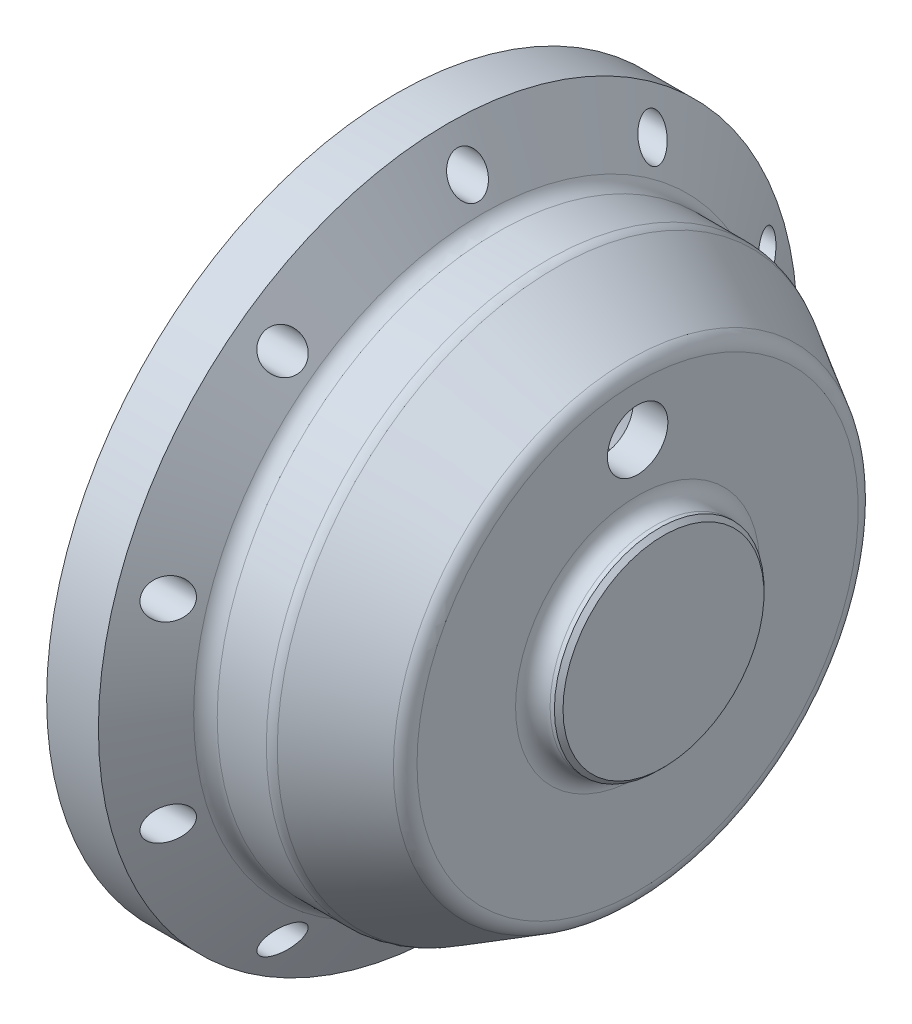
from build123d import *

# Parameters (mm, degrees)
CIRPATTERN1_COUNT        = 10
F_7_0_7_DIAMETER_HOLE1_D = 7


with BuildPart() as part:
    # Sketch1 → Revolve1 (revolve)
    with BuildSketch(Plane.XY):
        with BuildLine():
            Line((0, 40.5), (0, 30.475))
            Line((0, 30.475), (-1, 30.475))
            Line((-1, 30.475), (-1, 25.475))
            Line((-1, 25.475), (22, 25.475))
            ThreePointArc((22, 25.475), (23.414213562, 24.889213562), (24, 23.475))
            Line((24, 23.475), (24, 12.65))
            ThreePointArc((24, 12.65), (23.853553391, 12.296446609), (23.5, 12.15))
            Line((23.5, 12.15), (7.5, 12.15))
            Line((7.5, 12.15), (7.5, 11.15))
            Line((7.5, 11.15), (10, 11.15))
            Line((10, 11.15), (10, 7.5))
            Line((10, 7.5), (26.5, 7.5))
            ThreePointArc((26.5, 7.5), (26.853553391, 7.353553391), (27, 7))
            Line((27, 7), (27, 0))
            Line((27, 0), (31, 0))
            Line((31, 0), (31, 11.65))
            Line((31, 11.65), (30.5, 12.15))
            Line((30.5, 12.15), (30, 12.15))
            ThreePointArc((30, 12.15), (28.585786438, 12.735786438), (28, 14.15))
            Line((28, 14.15), (28, 25.57179677))
            ThreePointArc((28, 25.57179677), (27.732050808, 26.57179677), (27, 27.303847577))
            Line((27, 27.303847577), (18.464101615, 32.232050808))
            ThreePointArc((18.464101615, 32.232050808), (17.981739705, 32.431851653), (17.464101615, 32.5))
            Line((17.464101615, 32.5), (11.773502692, 32.5))
            ThreePointArc((11.773502692, 32.5), (10.773502692, 32.767949192), (10.041451884, 33.5))
            Line((10.041451884, 33.5), (6, 40.5))
            Line((6, 40.5), (0, 40.5))
        make_face()
    revolve(axis=Axis((-90.220634621, 0, 0), (1, 0, 0)))

    # Sketch2 → Tapped Hole for M4x0.7 Helicoil1 (revolve, cut)
    with BuildSketch(Plane.ZX.offset(36.5)):
        Polygon((0, 0), (0, 13.5618073), (2.1, 12.3), (2.1, 0), align=None)
    tapped_hole_for_m4x0_7_helicoil1 = revolve(axis=Axis((-6.35, 36.5, 0), (1, 0, 0)), mode=Mode.SUBTRACT)

    # CirPattern1: Tapped Hole for M4x0.7 Helicoil1 ×10 about axis
    cirpattern1_axis = Axis((0, 0, 0), (1, 0, 0))
    for i in range(1, CIRPATTERN1_COUNT):
        add(tapped_hole_for_m4x0_7_helicoil1.rotate(cirpattern1_axis, i * 360 / CIRPATTERN1_COUNT), mode=Mode.SUBTRACT)

    # Ø7.0 (7) Diameter Hole1 (through all)
    with Locations(Plane(origin=(0, 0, 0), x_dir=(0, 0, -1), z_dir=(-1, 0, 0))):
        with Locations((0, -19.75)):
            Hole(F_7_0_7_DIAMETER_HOLE1_D / 2)


solid = part.part
